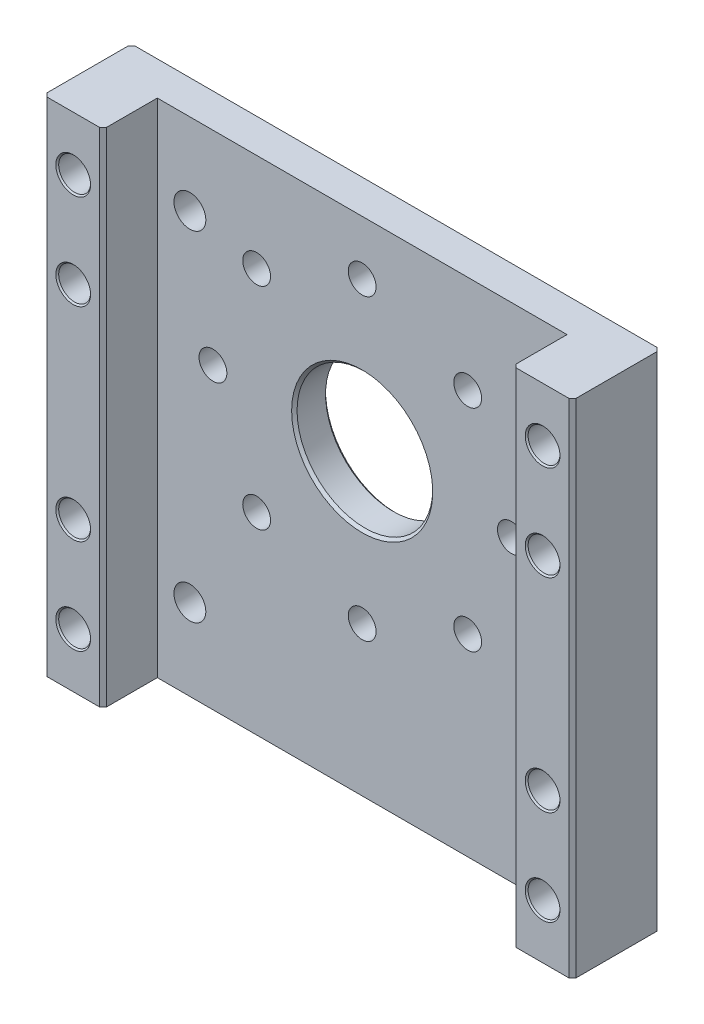
from build123d import *

# Parameters (mm, degrees)
SKETCH1_W                        = 39
SKETCH1_H                        = 37
BOSS_EXTRUDE1_DEPTH              = 6.5
SKETCH2_W                        = 30.2
SKETCH2_H                        = 4
CUT_EXTRUDE1_DEPTH               = 38
F_10_0_10_DIAMETER_HOLE1_D       = 10
F_10_0_10_DIAMETER_HOLE1_DEPTH   = 2.5
F_2_05_2_05_DIAMETER_HOLE1_D     = 2.05
F_2_05_2_05_DIAMETER_HOLE1_DEPTH = 6.5
F_2_05_2_05_DIAMETER_HOLE2_D     = 2.05
F_2_05_2_05_DIAMETER_HOLE2_DEPTH = 6.5
F_2_05_2_05_DIAMETER_HOLE3_D     = 2.05
F_2_05_2_05_DIAMETER_HOLE3_DEPTH = 6.5
CHAMFER1_SIZE                    = 0.25625
CHAMFER2_SIZE2                   = 0.199948225
CHAMFER2_SIZE                    = 0.199946154
SKETCH11_R                       = 1.28125
BOSS_EXTRUDE3_DEPTH              = 2.5
SKETCH12_R                       = 1.175
CUT_EXTRUDE2_DEPTH               = 7.5


with BuildPart() as part:
    # Sketch1 → Boss-Extrude1 (new body)
    with BuildSketch(Plane.XY.offset(-17)):
        with Locations((0, -3.5)):
            Rectangle(SKETCH1_W, SKETCH1_H)
    extrude(amount=-BOSS_EXTRUDE1_DEPTH)

    # Sketch2 → Cut-Extrude1 (cut, through all)
    with BuildSketch(Plane.XZ.offset(22)):
        with Locations((0, -19)):
            Rectangle(SKETCH2_W, SKETCH2_H)
    extrude(amount=-CUT_EXTRUDE1_DEPTH, mode=Mode.SUBTRACT)

    # Ø10.0 (10) Diameter Hole1
    with Locations(Plane.XY.offset(-21)):
        with Locations((0, 0)):
            Hole(F_10_0_10_DIAMETER_HOLE1_D / 2, depth=F_10_0_10_DIAMETER_HOLE1_DEPTH)

    # Ø2.05 (2.05) Diameter Hole1
    with Locations(Plane(origin=(0, 0, -23.5), x_dir=(-1, 0, 0), z_dir=(0, 0, -1))):
        with Locations((-17.3, -18), (17.3, -18), (-17.3, -11), (17.3, -11)):
            Hole(F_2_05_2_05_DIAMETER_HOLE1_D / 2, depth=F_2_05_2_05_DIAMETER_HOLE1_DEPTH)

    # Ø2.05 (2.05) Diameter Hole2
    with Locations(Plane.XY.offset(-17)):
        with Locations((17.3, 4), (-17.3, 4), (17.3, 11), (-17.3, 11)):
            Hole(F_2_05_2_05_DIAMETER_HOLE2_D / 2, depth=F_2_05_2_05_DIAMETER_HOLE2_DEPTH)

    # Ø2.05 (2.05) Diameter Hole3
    with Locations(Plane(origin=(0, 0, -23.5), x_dir=(-1, 0, 0), z_dir=(0, 0, -1))):
        with Locations((0, 11), (-7.778174593, 7.778174593), (-11, 0), (-7.778174593, -7.778174593), (0, -11), (7.778174593, -7.778174593), (11, 0), (7.778174593, 7.778174593), (13, 11), (-13, 11), (13, -17), (-13, -17)):
            Hole(F_2_05_2_05_DIAMETER_HOLE3_D / 2, depth=F_2_05_2_05_DIAMETER_HOLE3_DEPTH)

    # Chamfer1
    chamfer1_edges = [part.edges().sort_by_distance(p)[0] for p in [
        (-19.5, -3.5, -23.5),
        (-8.803174593, 7.778174593, -23.5),
        (-12.025, 0, -23.5),
        (-8.803174593, -7.778174593, -23.5),
        (-1.025, -11, -23.5),
        (6.753174593, -7.778174593, -23.5),
        (9.975, 0, -23.5),
        (6.753174593, 7.778174593, -23.5),
        (-1.025, 11, -23.5),
        (15.1, -3.5, -17),
        (-15.1, -3.5, -17),
        (-18.325, -11, -23.5),
        (-18.325, -11, -17),
        (19.5, -3.5, -23.5),
        (16.275, -11, -23.5),
        (16.275, -11, -17),
        (-18.325, -18, -23.5),
        (-18.325, -18, -17),
        (16.275, -18, -23.5),
        (16.275, -18, -17),
        (-19.5, -3.5, -17),
        (-16.275, 11, -17),
        (-16.275, 11, -23.5),
        (19.5, -3.5, -17),
        (18.325, 11, -17),
        (18.325, 11, -23.5),
        (-16.275, 4, -17),
        (-16.275, 4, -23.5),
        (18.325, 4, -17),
        (18.325, 4, -23.5),
        (11.975, -17, -23.5),
        (-14.025, -17, -23.5),
        (11.975, 11, -23.5),
        (-14.025, 11, -23.5),
    ]]
    chamfer(chamfer1_edges, length=CHAMFER1_SIZE)

    # Chamfer2
    chamfer2_edges = [part.edges().sort_by_distance(p)[0] for p in [
        (5, 0, -21),
        (5, 0, -23.5),
    ]]
    chamfer(chamfer2_edges, length=CHAMFER2_SIZE, length2=CHAMFER2_SIZE2)

    # Sketch11 → Boss-Extrude3 (add)
    with BuildSketch(Plane(origin=(0, 0, -23.5), x_dir=(-1, 0, 0), z_dir=(0, 0, -1))):
        with Locations((13, 11)):
            Circle(SKETCH11_R)
        with Locations((13, -17)):
            Circle(SKETCH11_R)
        with Locations((-13, -17)):
            Circle(SKETCH11_R)
        with Locations((-13, 11)):
            Circle(SKETCH11_R)
    extrude(amount=-BOSS_EXTRUDE3_DEPTH)

    # Sketch12 → Cut-Extrude2 (cut, through all)
    with BuildSketch(Plane.XY.offset(-17)):
        with Locations((12.7, 9)):
            Circle(SKETCH12_R)
        with Locations((-12.7, 9)):
            Circle(SKETCH12_R)
        with Locations((12.7, -16)):
            Circle(SKETCH12_R)
        with Locations((-12.7, -16)):
            Circle(SKETCH12_R)
        with Locations((-17.3, -18)):
            Circle(SKETCH12_R)
        with Locations((-17.3, -11)):
            Circle(SKETCH12_R)
        with Locations((-17.3, 4)):
            Circle(SKETCH12_R)
        with Locations((-17.3, 11)):
            Circle(SKETCH12_R)
        with Locations((17.3, -18)):
            Circle(SKETCH12_R)
        with Locations((17.3, -11)):
            Circle(SKETCH12_R)
        with Locations((17.3, 4)):
            Circle(SKETCH12_R)
        with Locations((17.3, 11)):
            Circle(SKETCH12_R)
    extrude(amount=-CUT_EXTRUDE2_DEPTH, mode=Mode.SUBTRACT)


solid = part.part
